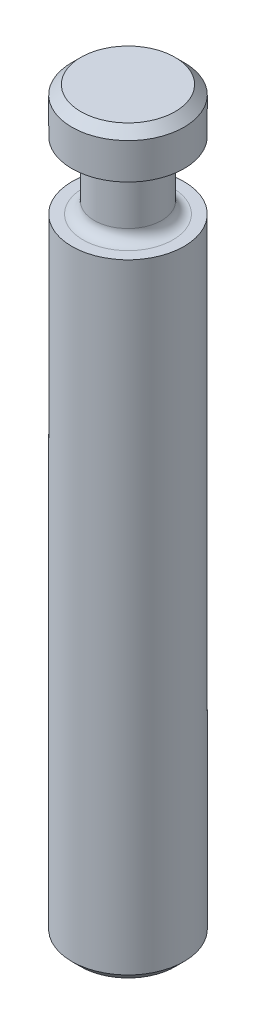
from build123d import *

# Parameters (mm, degrees)
SKETCH1_R      = 1.25
EXTRUDE1_DEPTH = 16.5
CHAMFER1_SIZE  = 0.2
SKETCH2_R      = 1.25
SKETCH2_R_2    = 0.75
EXTRUDE2_DEPTH = 1.5
FILLET1_R      = 0.25


with BuildPart() as part:
    # Sketch1 → Extrude1 (new body)
    with BuildSketch(Plane(origin=(0, 0, 0), x_dir=(1, 0, 0), z_dir=(0, 1, 0))):
        with Locations(Location((0, 0, 0), (0, 0, 270))):  # turned: the seam where the file's is
            Circle(SKETCH1_R)
    extrude(amount=-EXTRUDE1_DEPTH)

    # Chamfer1
    chamfer1_edges = [part.edges().sort_by_distance(p)[0] for p in [
        (0, 0, -1.25),
        (0, -16.5, -1.25),
    ]]
    chamfer(chamfer1_edges, length=CHAMFER1_SIZE)

    # Sketch2 → Extrude2 (cut)
    with BuildSketch(Plane.XZ.offset(2.5)):
        with Locations(Location((0, 0, 0), (0, 0, 90))):  # turned: the seam where the file's is
            Circle(SKETCH2_R)
        with Locations(Location((0, 0, 0), (0, 0, 270))):  # turned: the seam where the file's is
            Circle(SKETCH2_R_2, mode=Mode.SUBTRACT)
    extrude(amount=-EXTRUDE2_DEPTH, mode=Mode.SUBTRACT)

    # Fillet1
    fillet1_edges = [part.edges().sort_by_distance(p)[0] for p in [
        (0, -1, 0.75),
        (0, -2.5, 0.75),
    ]]
    fillet(fillet1_edges, radius=FILLET1_R)


solid = part.part
